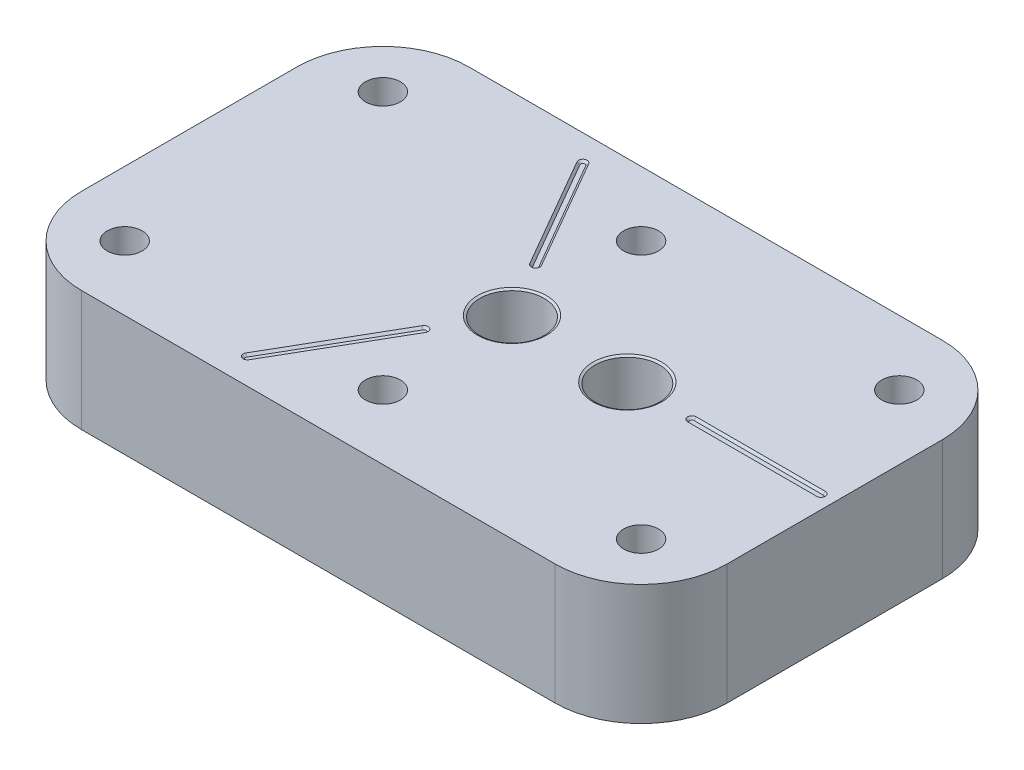
from build123d import *

# Parameters (mm, degrees)
SKETCH1_W                                   = 190.5
SKETCH1_H                                   = 114.3
EXTRUDE1_DEPTH                              = 35.56
F_3_8_CLEARANCE_HOLE1_D                     = 10.31748
LPATTERN6_COUNT                             = 3
LPATTERN6_PITCH                             = 76.2
LPATTERN6_COUNT_DIR2                        = 2
LPATTERN6_PITCH_DIR2                        = 76.2
F_5_8_11_TAPPED_HOLE1_D                     = 15.875
F_5_8_11_TAPPED_HOLE1_CSINK_D               = 17.145
F_5_8_11_TAPPED_HOLE1_CSINK_ANGLE           = 120
FILLET1_R                                   = 25.4
EXTRUDE2_DEPTH                              = 0.635
EXTRUDE2_TAPER                              = 45
TAPPED_HOLE_FOR_5_8_11_HELICOIL2_AT_2_COUNT = 2
TAPPED_HOLE_FOR_5_8_11_HELICOIL2_AT_2_PITCH = 34.036


with BuildPart() as part:
    # Sketch1 → Extrude1 (new body)
    with BuildSketch(Plane(origin=(0, 0, 0), x_dir=(1, 0, 0), z_dir=(0, 1, 0))):
        Rectangle(SKETCH1_W, SKETCH1_H)
    extrude(amount=EXTRUDE1_DEPTH)

    # 3/8 Clearance Hole1 (through all)
    with Locations(Plane(origin=(0, 35.56, 0), x_dir=(-1, 0, 0), z_dir=(0, 1, 0))):
        with Locations((76.2, -38.1)):
            f_3_8_clearance_hole1 = Hole(F_3_8_CLEARANCE_HOLE1_D / 2)

    # LPattern6: 3_8 Clearance Hole1 3 × 2
    with Locations(*[(i * LPATTERN6_PITCH, 0, j * LPATTERN6_PITCH_DIR2) for i in range(LPATTERN6_COUNT) for j in range(LPATTERN6_COUNT_DIR2) if (i, j) != (0, 0)]):
        add(f_3_8_clearance_hole1, mode=Mode.SUBTRACT)

    # 5/8-11 Tapped Hole1 (through all)
    with Locations(Plane(origin=(0, 35.56, 0), x_dir=(-1, 0, 0), z_dir=(0, 1, 0))):
        with Locations((0, 0), (-34.036, 0)):
            CounterSinkHole(F_5_8_11_TAPPED_HOLE1_D / 2, F_5_8_11_TAPPED_HOLE1_CSINK_D / 2, counter_sink_angle=F_5_8_11_TAPPED_HOLE1_CSINK_ANGLE)

    # Fillet1
    fillet1_edges = [part.edges().sort_by_distance(p)[0] for p in [
        (95.25, 17.78, 57.15),
        (-95.25, 17.78, 57.15),
        (-95.25, 17.78, -57.15),
        (95.25, 17.78, -57.15),
    ]]
    fillet(fillet1_edges, radius=FILLET1_R)

    # Sketch6 → Extrude2 (cut)
    with BuildSketch(Plane(origin=(0, 35.56, 0), x_dir=(1, 0, 0), z_dir=(0, 1, 0))):
        with BuildLine():
            Line((-8.425147737, 17.132783942), (-27.475147737, 50.128351826))
            ThreePointArc((-27.475147737, 50.128351826), (-29.21, 50.593204089), (-29.674852263, 48.858351826))
            Line((-29.674852263, 48.858351826), (-10.624852263, 15.862783942))
            ThreePointArc((-10.624852263, 15.862783942), (-8.89, 15.397931679), (-8.425147737, 17.132783942))
        make_face()
        with BuildLine():
            Line((-10.624852263, -15.862783942), (-29.674852263, -48.858351826))
            ThreePointArc((-29.674852263, -48.858351826), (-29.21, -50.593204089), (-27.475147737, -50.128351826))
            Line((-27.475147737, -50.128351826), (-8.425147737, -17.132783942))
            ThreePointArc((-8.425147737, -17.132783942), (-8.89, -15.397931679), (-10.624852263, -15.862783942))
        make_face()
        with BuildLine():
            Line((53.086, -1.27), (91.186, -1.27))
            ThreePointArc((91.186, -1.27), (92.456, 0), (91.186, 1.27))
            Line((91.186, 1.27), (53.086, 1.27))
            ThreePointArc((53.086, 1.27), (51.816, 0), (53.086, -1.27))
        make_face()
    extrude(amount=-EXTRUDE2_DEPTH, taper=EXTRUDE2_TAPER, mode=Mode.SUBTRACT)

    # Sketch9 → Tapped Hole for 5/8-11 Helicoil2 (revolve, cut)
    with BuildSketch(Plane(origin=(0, 35.56, 0), x_dir=(0, 0, 1), z_dir=(1, 0, 0))):
        Polygon((0, 0), (0, 43.056616175), (8.33374, 38.0492), (8.33374, 27.7876), (9.49579, 27.7876), (9.49579, 0.383481822), (10.16, 0), align=None)
    tapped_hole_for_5_8_11_helicoil2 = revolve(axis=Axis((0, 41.91, 0), (0, -1, 0)), mode=Mode.SUBTRACT)

    # Tapped Hole for 5/8-11 Helicoil2 at 2: Tapped Hole for 5/8-11 Helicoil2 ×2
    with Locations(*[(i * TAPPED_HOLE_FOR_5_8_11_HELICOIL2_AT_2_PITCH, 0, 0) for i in range(1, TAPPED_HOLE_FOR_5_8_11_HELICOIL2_AT_2_COUNT)]):
        add(tapped_hole_for_5_8_11_helicoil2, mode=Mode.SUBTRACT)


solid = part.part
